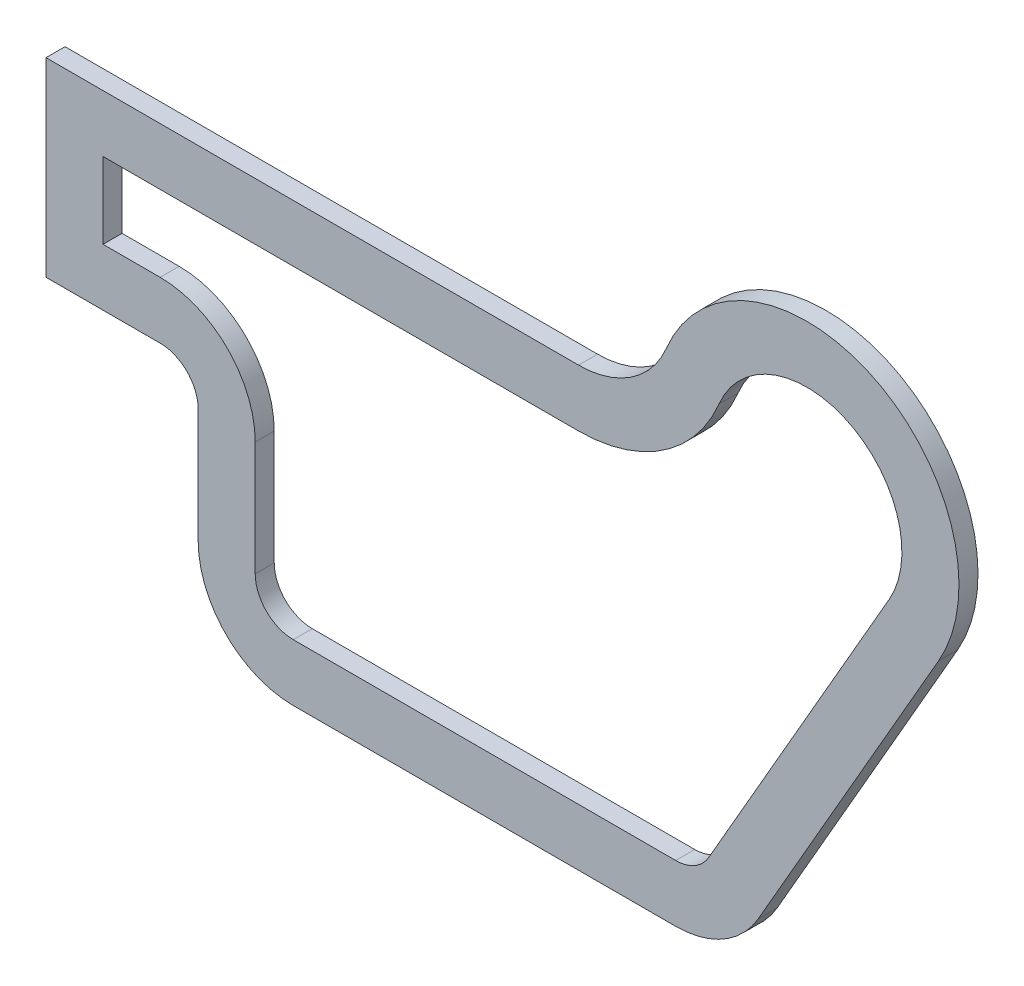
from build123d import *

# Parameters (mm, degrees)
BOSS_EXTRUDE1_DEPTH = 5
SHELL1_T            = -15


with BuildPart() as part:
    # Sketch1 → Boss-Extrude1 (new body)
    with BuildSketch(Plane.XY):
        with BuildLine():
            Line((140, 181.335972228), (0, 181.335972228))
            Line((0, 181.335972228), (0, 131.335972228))
            Line((0, 131.335972228), (30, 131.335972228))
            ThreePointArc((30, 131.335972228), (37.071067812, 128.40704004), (40, 121.335972228))
            Line((40, 121.335972228), (40, 91.335972228))
            ThreePointArc((40, 91.335972228), (47.32233047, 73.658302699), (65, 66.335972228))
            Line((65, 66.335972228), (165.538941775, 66.335972228))
            ThreePointArc((165.538941775, 66.335972228), (178.05666204, 69.695577607), (187.210014279, 78.87143788))
            Line((187.210014279, 78.87143788), (234.673716006, 161.392717271))
            ThreePointArc((234.673716006, 161.392717271), (217.699703722, 217.206858587), (163.076923077, 196.720587613))
            ThreePointArc((163.076923077, 196.720587613), (153.867504906, 185.53471487), (140, 181.335972228))
        make_face()
    extrude(amount=BOSS_EXTRUDE1_DEPTH)

    # Shell1
    shell1_openings = [part.faces().sort_by_distance(p)[0] for p in [
        (98.657145907, 130.57403932, 5),
        (98.657145907, 130.57403932, 0),
    ]]
    offset(amount=SHELL1_T, openings=shell1_openings, kind=Kind.INTERSECTION)


solid = part.part
